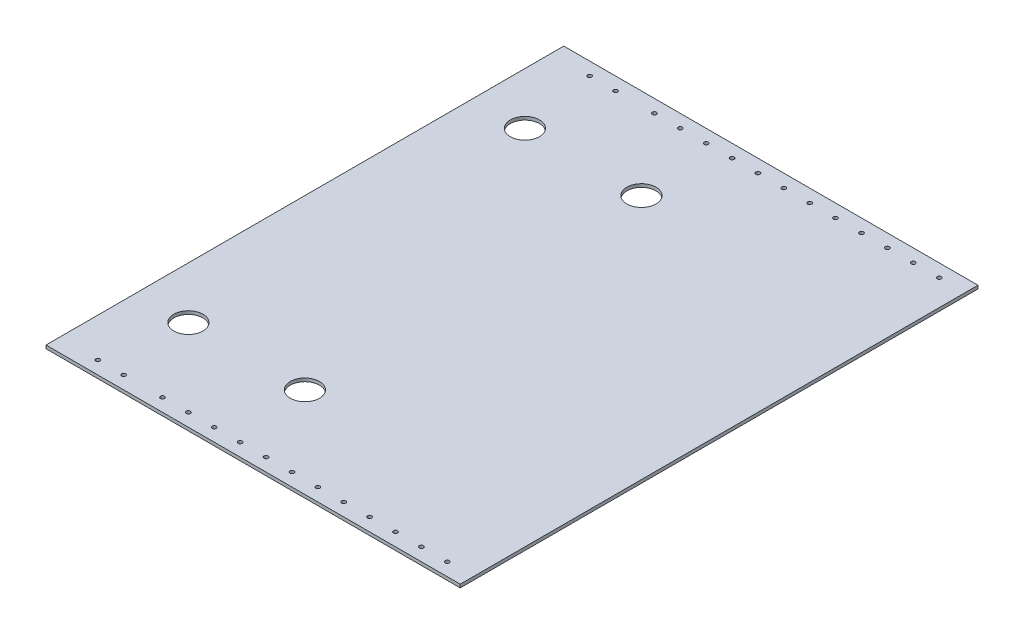
from build123d import *

# Parameters (mm, degrees)
SKETCH1_W               = 571.5
SKETCH1_H               = 508
BOSS_EXTRUDE1_DEPTH     = 3.175
SKETCH2_R               = 14.2875
CUT_EXTRUDE1_DEPTH      = 3.175
SKETCH4_R               = 2.0193
CUT_EXTRUDE3_DEPTH      = 1
CUT_EXTRUDE3_DEPTH_BACK = 4.175
SKETCH5_W               = 619.579537293
SKETCH5_H               = 89.035098343
CUT_EXTRUDE4_DEPTH      = 165.1


with BuildPart() as part:
    # Sketch1 → Boss-Extrude1 (new body)
    with BuildSketch(Plane(origin=(0, 0, 0), x_dir=(1, 0, 0), z_dir=(0, 1, 0))):
        with Locations((285.75, 254)):
            Rectangle(SKETCH1_W, SKETCH1_H)
    extrude(amount=BOSS_EXTRUDE1_DEPTH)

    # Sketch2 → Cut-Extrude1 (cut)
    with BuildSketch(Plane(origin=(0, 3.175, 0), x_dir=(1, 0, 0), z_dir=(0, 1, 0))):
        with Locations((215.9, 419.1)):
            Circle(SKETCH2_R)
        with Locations((330.2, 419.1)):
            Circle(SKETCH2_R)
        with Locations((215.9, 88.9)):
            Circle(SKETCH2_R)
        with Locations((330.2, 88.9)):
            Circle(SKETCH2_R)
    extrude(amount=-CUT_EXTRUDE1_DEPTH, mode=Mode.SUBTRACT)

    # Sketch4 → Cut-Extrude3 (cut, two sides)
    with BuildSketch(Plane(origin=(0, 3.175, 0), x_dir=(1, 0, 0), z_dir=(0, 1, 0))) as cut_extrude3_sk:
        with Locations((546.1, 495.3)):
            Circle(SKETCH4_R)
        with Locations((520.7, 495.3)):
            Circle(SKETCH4_R)
        with Locations((495.3, 495.3)):
            Circle(SKETCH4_R)
        with Locations((469.9, 495.3)):
            Circle(SKETCH4_R)
        with Locations((444.5, 495.3)):
            Circle(SKETCH4_R)
        with Locations((419.1, 495.3)):
            Circle(SKETCH4_R)
        with Locations((393.7, 495.3)):
            Circle(SKETCH4_R)
        with Locations((368.3, 495.3)):
            Circle(SKETCH4_R)
        with Locations((342.9, 495.3)):
            Circle(SKETCH4_R)
        with Locations((317.5, 495.3)):
            Circle(SKETCH4_R)
        with Locations((292.1, 495.3)):
            Circle(SKETCH4_R)
        with Locations((266.7, 495.3)):
            Circle(SKETCH4_R)
        with Locations((228.6, 495.3)):
            Circle(SKETCH4_R)
        with Locations((203.2, 495.3)):
            Circle(SKETCH4_R)
        with Locations((203.2, 12.7)):
            Circle(SKETCH4_R)
        with Locations((228.6, 12.7)):
            Circle(SKETCH4_R)
        with Locations((266.7, 12.7)):
            Circle(SKETCH4_R)
        with Locations((292.1, 12.7)):
            Circle(SKETCH4_R)
        with Locations((317.5, 12.7)):
            Circle(SKETCH4_R)
        with Locations((342.9, 12.7)):
            Circle(SKETCH4_R)
        with Locations((368.3, 12.7)):
            Circle(SKETCH4_R)
        with Locations((393.7, 12.7)):
            Circle(SKETCH4_R)
        with Locations((419.1, 12.7)):
            Circle(SKETCH4_R)
        with Locations((444.5, 12.7)):
            Circle(SKETCH4_R)
        with Locations((469.9, 12.7)):
            Circle(SKETCH4_R)
        with Locations((495.3, 12.7)):
            Circle(SKETCH4_R)
        with Locations((520.7, 12.7)):
            Circle(SKETCH4_R)
        with Locations((546.1, 12.7)):
            Circle(SKETCH4_R)
    extrude(amount=CUT_EXTRUDE3_DEPTH, mode=Mode.SUBTRACT)
    extrude(cut_extrude3_sk.sketch, amount=-CUT_EXTRUDE3_DEPTH_BACK, mode=Mode.SUBTRACT)

    # Sketch5 → Cut-Extrude4 (cut)
    with BuildSketch(Plane.ZY):
        with Locations((-257.641209254, 26.710529503)):
            Rectangle(SKETCH5_W, SKETCH5_H)
    extrude(amount=-CUT_EXTRUDE4_DEPTH, mode=Mode.SUBTRACT)


solid = part.part
